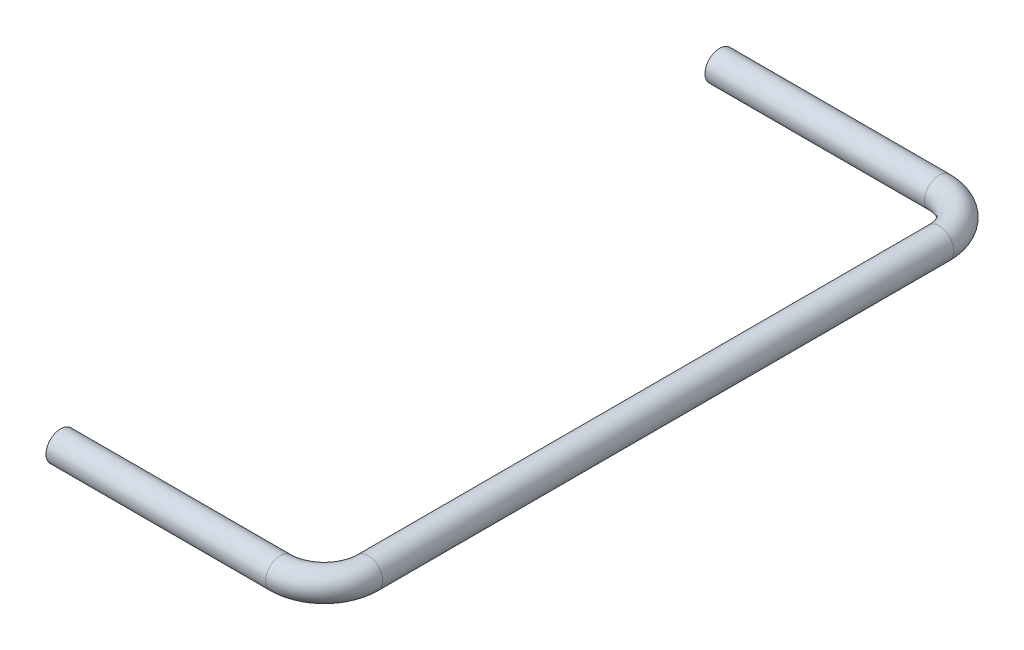
from build123d import *

# Parameters (mm, degrees)
SKETCH_1_R = 1


with BuildPart() as part:
    # По траектории1: sweep along a curve in space
    with BuildLine() as sweep_1_path:
        Line((0, 0, 0), (15, 0, 0))
        ThreePointArc((15, 0, 0), (17.121320344, 0, -0.878679656), (18, 0, -3))
        Line((18, 0, -3), (18, 0, -42))
        ThreePointArc((18, 0, -42), (17.121320344, 0, -44.121320344), (15, 0, -45))
        Line((15, 0, -45), (0, 0, -45))
    # Эскиз1 → По траектории1 (sweep)
    with BuildSketch(Plane(origin=(0, 0, 0), x_dir=(0, 0, -1), z_dir=(1, 0, 0))):
        Circle(SKETCH_1_R)
    sweep(path=sweep_1_path.line)


solid = part.part
